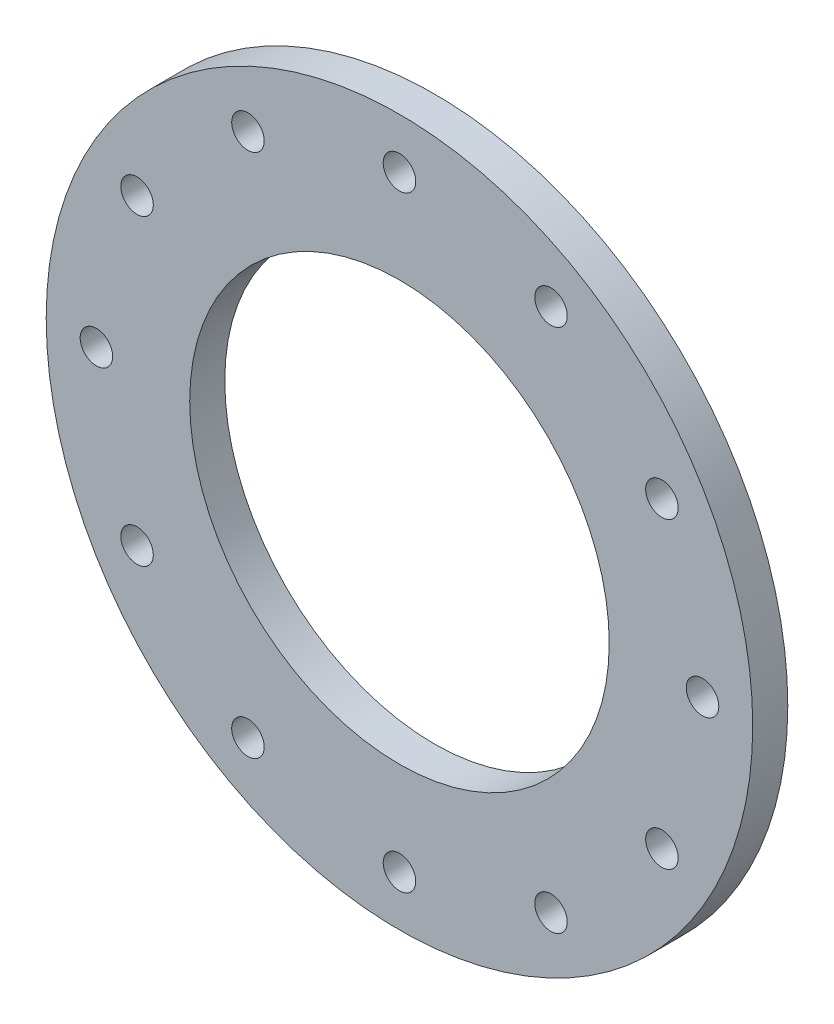
from build123d import *

# Parameters (mm, degrees)
SKETCH1_R           = 32
SKETCH1_R_2         = 1.4732
SKETCH1_R_3         = 19
BOSS_EXTRUDE1_DEPTH = 3.175


with BuildPart() as part:
    # Sketch1 → Boss-Extrude1 (new body)
    with BuildSketch(Plane.XY.offset(0.2)):
        with Locations((-17.5, -28.25)):
            Circle(SKETCH1_R)
        with Locations((-17.5, -55.7)):
            Circle(SKETCH1_R_2, mode=Mode.SUBTRACT)
        with Locations((-31.225, -52.022397334)):
            Circle(SKETCH1_R_2, mode=Mode.SUBTRACT)
        with Locations((-41.272397334, -41.975)):
            Circle(SKETCH1_R_2, mode=Mode.SUBTRACT)
        with Locations((-44.95, -28.25)):
            Circle(SKETCH1_R_2, mode=Mode.SUBTRACT)
        with Locations((-41.272397334, -14.525)):
            Circle(SKETCH1_R_2, mode=Mode.SUBTRACT)
        with Locations((-31.225, -4.477602666)):
            Circle(SKETCH1_R_2, mode=Mode.SUBTRACT)
        with Locations((-17.5, -0.8)):
            Circle(SKETCH1_R_2, mode=Mode.SUBTRACT)
        with Locations((-3.775, -4.477602666)):
            Circle(SKETCH1_R_2, mode=Mode.SUBTRACT)
        with Locations((6.272397334, -14.525)):
            Circle(SKETCH1_R_2, mode=Mode.SUBTRACT)
        with Locations((9.95, -28.25)):
            Circle(SKETCH1_R_2, mode=Mode.SUBTRACT)
        with Locations((6.272397334, -41.975)):
            Circle(SKETCH1_R_2, mode=Mode.SUBTRACT)
        with Locations((-3.775, -52.022397334)):
            Circle(SKETCH1_R_2, mode=Mode.SUBTRACT)
        with Locations((-17.5, -28.25)):
            Circle(SKETCH1_R_3, mode=Mode.SUBTRACT)
    extrude(amount=BOSS_EXTRUDE1_DEPTH)


solid = part.part
